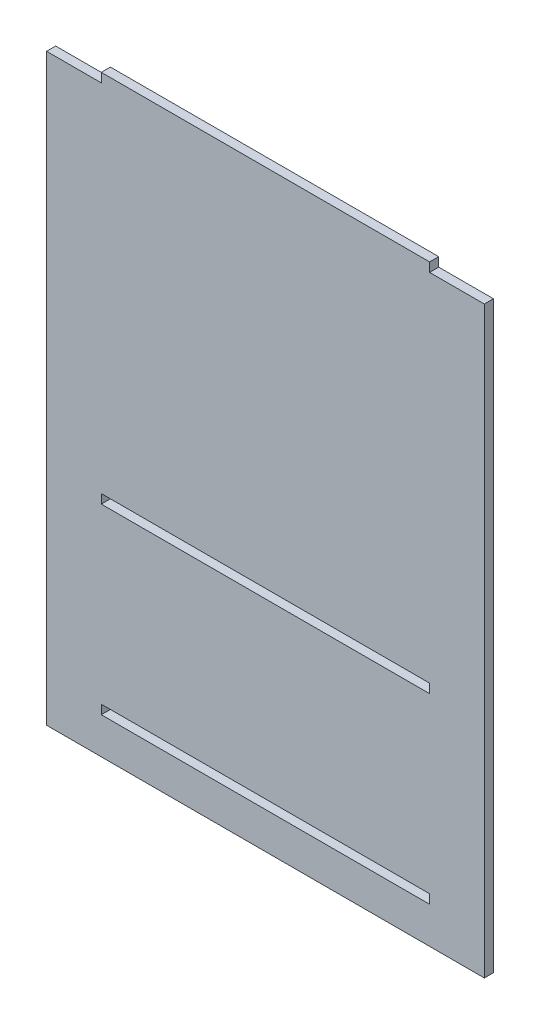
from build123d import *

# Parameters (mm, degrees)
SKETCH2_W           = 114.3
SKETCH2_H           = 3.175
BOSS_EXTRUDE1_DEPTH = 3.175


with BuildPart() as part:
    # Sketch2 → Boss-Extrude1 (new body)
    with BuildSketch(Plane.XY):
        Polygon((133.35, 0), (152.4, 0), (152.4, 203.2), (133.35, 203.2), (133.35, 206.375), (19.05, 206.375), (19.05, 203.2), (0, 203.2), (0, 0), (19.05, 0), align=None)
        with Locations((76.2, 14.2875)):
            Rectangle(SKETCH2_W, SKETCH2_H, mode=Mode.SUBTRACT)
        with Locations((76.2, 77.7875)):
            Rectangle(SKETCH2_W, SKETCH2_H, mode=Mode.SUBTRACT)
    extrude(amount=BOSS_EXTRUDE1_DEPTH)


solid = part.part
